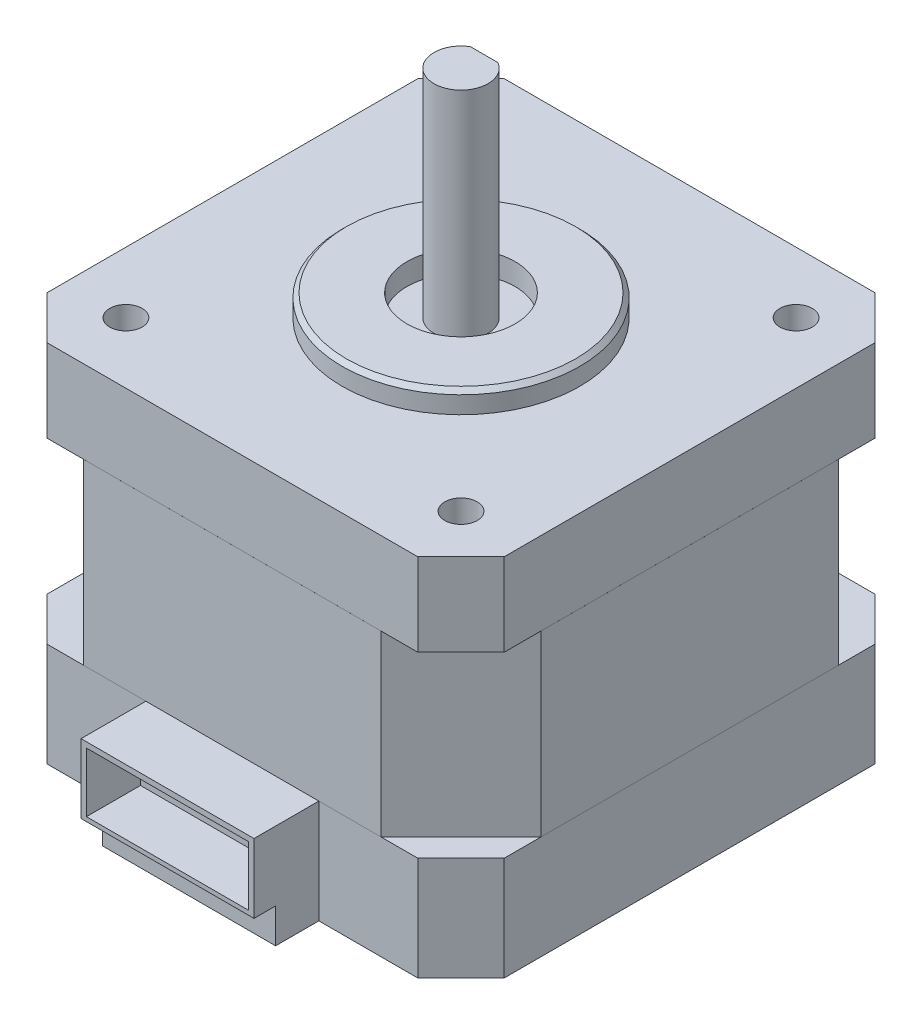
from build123d import *

# Parameters (mm, degrees)
EXTRUDE1_START       = -17
SKETCH1_W            = 42.3
SKETCH1_H            = 42.3
EXTRUDE1_DEPTH       = 9.6
CHAMFER3_SIZE        = 4
BOSS_EXTRUDE8_DEPTH  = 16.5
BOSS_EXTRUDE9_DEPTH  = 7.65
SKETCH33_R           = 11
BOSS_EXTRUDE10_DEPTH = 2
SKETCH34_R           = 5
CUT_EXTRUDE1_DEPTH   = 2
SKETCH35_R           = 2.5
BOSS_EXTRUDE11_DEPTH = 20
CUT_EXTRUDE3_DEPTH   = 15
SKETCH37_W           = 27.5
SKETCH37_H           = 16.5
BOSS_EXTRUDE12_DEPTH = 0.001
SKETCH38_W           = 27.5
SKETCH38_H           = 16.5
BOSS_EXTRUDE13_DEPTH = 0.001
SKETCH39_W           = 27.5
SKETCH39_H           = 16.5
BOSS_EXTRUDE14_DEPTH = 0.001
SKETCH40_W           = 27.5
SKETCH40_H           = 16.5
BOSS_EXTRUDE15_DEPTH = 0.001
SKETCH41_R           = 1.5
CUT_EXTRUDE4_DEPTH   = 6
SKETCH42_R           = 4.5
SKETCH42_R_2         = 1.5
CUT_EXTRUDE5_DEPTH   = 3
SKETCH43_W           = 16
SKETCH43_H           = 4
BOSS_EXTRUDE16_DEPTH = 3.2
SKETCH44_W           = 16
SKETCH44_H           = 6.4
BOSS_EXTRUDE17_DEPTH = 6
SKETCH45_W           = 15
SKETCH45_H           = 5.5
CUT_EXTRUDE6_DEPTH   = 5
SKETCH46_R           = 1.5
BOSS_EXTRUDE18_DEPTH = 1.5
CHAMFER4_SIZE        = 0.4


with BuildPart() as part:
    # Sketch1 → Extrude1 (new body)
    with BuildSketch(Plane(origin=(0, 0, 0), x_dir=(1, 0, 0), z_dir=(0, 1, 0)).offset(EXTRUDE1_START)):
        Rectangle(SKETCH1_W, SKETCH1_H)
    extrude(amount=EXTRUDE1_DEPTH)

    # Chamfer3
    chamfer3_edges = [part.edges().sort_by_distance(p)[0] for p in [
        (-21.15, -12.2, -21.15),
        (21.15, -12.2, -21.15),
        (21.15, -12.2, 21.15),
        (-21.15, -12.2, 21.15),
    ]]
    chamfer(chamfer3_edges, length=CHAMFER3_SIZE)

    # Sketch31 → Boss-Extrude8 (add)
    with BuildSketch(Plane(origin=(0, -7.4, 0), x_dir=(1, 0, 0), z_dir=(0, 1, 0))):
        Polygon((-13.75, 21.15), (13.75, 21.15), (21.15, 13.75), (21.15, -13.75), (13.75, -21.15), (-13.75, -21.15), (-21.15, -13.75), (-21.15, 13.75), align=None)
    extrude(amount=BOSS_EXTRUDE8_DEPTH)

    # Sketch32 → Boss-Extrude9 (add)
    with BuildSketch(Plane(origin=(0, 9.1, 0), x_dir=(1, 0, 0), z_dir=(0, 1, 0))):
        Polygon((-17.15, 21.15), (-21.15, 17.15), (-21.15, 13.75), (-21.15, -13.75), (-21.15, -17.15), (-17.15, -21.15), (-13.75, -21.15), (13.75, -21.15), (17.15, -21.15), (21.15, -17.15), (21.15, -13.75), (21.15, 13.75), (21.15, 17.15), (17.15, 21.15), (13.75, 21.15), (-13.75, 21.15), align=None)
    extrude(amount=BOSS_EXTRUDE9_DEPTH)

    # Sketch33 → Boss-Extrude10 (add)
    with BuildSketch(Plane(origin=(0, 16.75, 0), x_dir=(1, 0, 0), z_dir=(0, 1, 0))):
        Circle(SKETCH33_R)
    extrude(amount=BOSS_EXTRUDE10_DEPTH)

    # Sketch34 → Cut-Extrude1 (cut)
    with BuildSketch(Plane(origin=(0, 18.75, 0), x_dir=(1, 0, 0), z_dir=(0, 1, 0))):
        Circle(SKETCH34_R)
    extrude(amount=-CUT_EXTRUDE1_DEPTH, mode=Mode.SUBTRACT)

    # Sketch35 → Boss-Extrude11 (add)
    with BuildSketch(Plane(origin=(0, 16.75, 0), x_dir=(1, 0, 0), z_dir=(0, 1, 0))):
        Circle(SKETCH35_R)
    extrude(amount=BOSS_EXTRUDE11_DEPTH)

    # Sketch36 → Cut-Extrude3 (cut)
    with BuildSketch(Plane(origin=(0, 36.75, 0), x_dir=(1, 0, 0), z_dir=(0, 1, 0))):
        with BuildLine():
            Line((-1.275735082, 2.15), (0, 2.15))
            Line((0, 2.15), (1.275735082, 2.15))
            ThreePointArc((1.275735082, 2.15), (0, 2.5), (-1.275735082, 2.15))
        make_face()
    extrude(amount=-CUT_EXTRUDE3_DEPTH, mode=Mode.SUBTRACT)

    # Sketch37 → Boss-Extrude12 (add)
    with BuildSketch(Plane(origin=(21.15, 0, 0), x_dir=(0, 0, -1), z_dir=(1, 0, 0))):
        with Locations((0, 0.85)):
            Rectangle(SKETCH37_W, SKETCH37_H)
    extrude(amount=BOSS_EXTRUDE12_DEPTH)

    # Sketch38 → Boss-Extrude13 (add)
    with BuildSketch(Plane.XY.offset(21.15)):
        with Locations((0, 0.85)):
            Rectangle(SKETCH38_W, SKETCH38_H)
    extrude(amount=BOSS_EXTRUDE13_DEPTH)

    # Sketch39 → Boss-Extrude14 (add)
    with BuildSketch(Plane.ZY.offset(21.15)):
        with Locations((0, 0.85)):
            Rectangle(SKETCH39_W, SKETCH39_H)
    extrude(amount=BOSS_EXTRUDE14_DEPTH)

    # Sketch40 → Boss-Extrude15 (add)
    with BuildSketch(Plane(origin=(0, 0, -21.15), x_dir=(-1, 0, 0), z_dir=(0, 0, -1))):
        with Locations((0, 0.85)):
            Rectangle(SKETCH40_W, SKETCH40_H)
    extrude(amount=BOSS_EXTRUDE15_DEPTH)

    # Sketch41 → Cut-Extrude4 (cut)
    with BuildSketch(Plane(origin=(0, 16.75, 0), x_dir=(1, 0, 0), z_dir=(0, 1, 0))):
        with Locations((-15.5, 15.5)):
            Circle(SKETCH41_R)
        with Locations((-15.5, -15.5)):
            Circle(SKETCH41_R)
        with Locations((15.5, -15.5)):
            Circle(SKETCH41_R)
        with Locations((15.5, 15.5)):
            Circle(SKETCH41_R)
    extrude(amount=-CUT_EXTRUDE4_DEPTH, mode=Mode.SUBTRACT)

    # Sketch42 → Cut-Extrude5 (cut)
    with BuildSketch(Plane.XZ.offset(17)):
        Circle(SKETCH42_R)
        with Locations((-15.5, 15.5)):
            Circle(SKETCH42_R_2)
        with Locations((15.5, 15.5)):
            Circle(SKETCH42_R_2)
        with Locations((15.5, -15.5)):
            Circle(SKETCH42_R_2)
        with Locations((-15.5, -15.5)):
            Circle(SKETCH42_R_2)
    extrude(amount=-CUT_EXTRUDE5_DEPTH, mode=Mode.SUBTRACT)

    # Sketch43 → Boss-Extrude16 (add)
    with BuildSketch(Plane.XZ.offset(17)):
        with Locations((0, 23.15)):
            Rectangle(SKETCH43_W, SKETCH43_H)
    extrude(amount=-BOSS_EXTRUDE16_DEPTH)

    # Sketch44 → Boss-Extrude17 (add)
    with BuildSketch(Plane.XY.offset(21.15)):
        with Locations((0, -10.6)):
            Rectangle(SKETCH44_W, SKETCH44_H)
    extrude(amount=BOSS_EXTRUDE17_DEPTH)

    # Sketch45 → Cut-Extrude6 (cut)
    with BuildSketch(Plane.XY.offset(27.15)):
        with Locations((0, -10.65)):
            Rectangle(SKETCH45_W, SKETCH45_H)
    extrude(amount=-CUT_EXTRUDE6_DEPTH, mode=Mode.SUBTRACT)

    # Sketch46 → Boss-Extrude18 (add)
    with BuildSketch(Plane(origin=(0, 10.75, 0), x_dir=(1, 0, 0), z_dir=(0, 1, 0))):
        with Locations((-15.5, -15.5)):
            Circle(SKETCH46_R)
        with Locations((-15.5, 15.5)):
            Circle(SKETCH46_R)
        with Locations((15.5, 15.5)):
            Circle(SKETCH46_R)
        with Locations((15.5, -15.5)):
            Circle(SKETCH46_R)
    extrude(amount=BOSS_EXTRUDE18_DEPTH)

    # Chamfer4
    chamfer4_edges = [part.edges().sort_by_distance(p)[0] for p in [
        (-11, 18.75, 0),
    ]]
    chamfer(chamfer4_edges, length=CHAMFER4_SIZE)


solid = part.part
